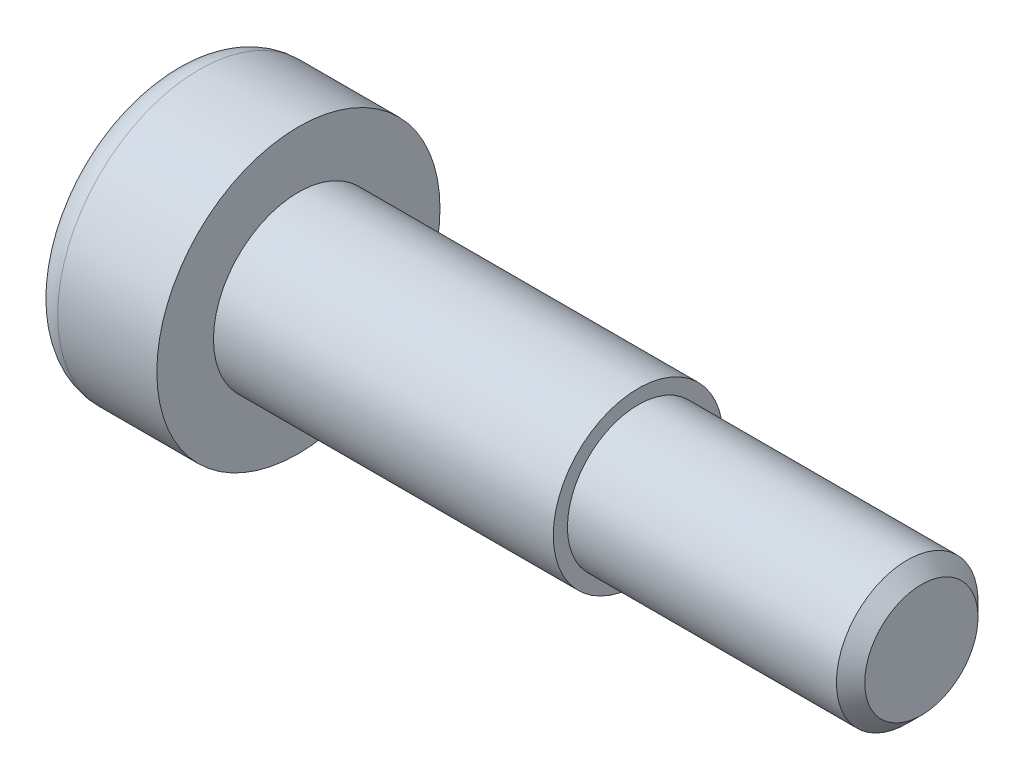
from build123d import *

# Parameters (mm, degrees)
CUT_EXTRUDE_1_DEPTH = 3
FILLET_1_R          = 1
CHAMFER_1_SIZE      = 0.5


with BuildPart() as part:
    # 草图1 → 旋转1 (revolve)
    with BuildSketch(Plane.XY):
        Polygon((0, 0), (0, 5), (4.5, 5), (4.5, 3), (16.5, 3), (16.5, 2.5), (26.5, 2.5), (26.5, 0), align=None)
    revolve(axis=Axis((0, 0, 0), (1, 0, 0)))

    # 草图2 → 切除-拉伸1 (cut)
    with BuildSketch(Plane.ZY):
        Polygon((0, 1.732050808), (-1.5, 0.866025404), (-1.5, -0.866025404), (0, -1.732050808), (1.5, -0.866025404), (1.5, 0.866025404), align=None)
    extrude(amount=-CUT_EXTRUDE_1_DEPTH, mode=Mode.SUBTRACT)

    # 圆角1
    fillet_1_edges = [part.edges().sort_by_distance(p)[0] for p in [
        (0, -5, 0),
    ]]
    fillet(fillet_1_edges, radius=FILLET_1_R)

    # 倒角1
    chamfer_1_edges = [part.edges().sort_by_distance(p)[0] for p in [
        (26.5, -2.5, 0),
    ]]
    chamfer(chamfer_1_edges, length=CHAMFER_1_SIZE)


solid = part.part
